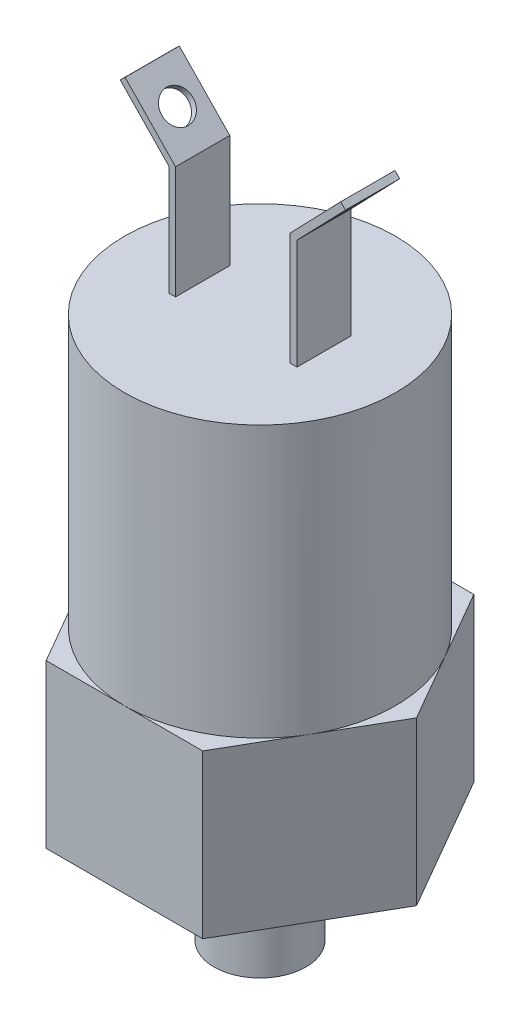
from build123d import *

# Parameters (mm, degrees)
BOSS_EXTRUDE1_DEPTH = 15.24
SKETCH3_R           = 12.7
BOSS_EXTRUDE2_DEPTH = 25.4
SKETCH4_R           = 4.3053
BOSS_EXTRUDE3_DEPTH = 10.16
EXTRUDE_THIN1_DEPTH = 2.54
SKETCH6_R           = 1.4605
CUT_EXTRUDE1_DEPTH  = 0.635


with BuildPart() as part:
    # Sketch2 → Boss-Extrude1 (new body)
    with BuildSketch(Plane(origin=(0, 0, 0), x_dir=(1, 0, 0), z_dir=(0, 1, 0))):
        Polygon((7.332348419, 12.7), (-7.332348419, 12.7), (-14.664696837, 0), (-7.332348419, -12.7), (7.332348419, -12.7), (14.664696837, 0), align=None)
    extrude(amount=BOSS_EXTRUDE1_DEPTH)

    # Sketch3 → Boss-Extrude2 (add)
    with BuildSketch(Plane(origin=(0, 15.24, 0), x_dir=(1, 0, 0), z_dir=(0, 1, 0))):
        Circle(SKETCH3_R)
    extrude(amount=BOSS_EXTRUDE2_DEPTH)

    # Sketch4 → Boss-Extrude3 (add)
    with BuildSketch(Plane.XZ):
        Circle(SKETCH4_R)
    extrude(amount=BOSS_EXTRUDE3_DEPTH)

    # Sketch5 → Extrude-Thin1 (add, symmetric)
    with BuildSketch(Plane.XY):
        Polygon((6.008182396, 40.64), (6.008182396, 50.946997676), (10.555270964, 55.659540341), (10.098307994, 56.100459659), (5.373182396, 51.203401761), (5.373182396, 40.64), align=None)
    extrude_thin1 = extrude(amount=EXTRUDE_THIN1_DEPTH, both=True)

    # Sketch6 → Cut-Extrude1 (cut)
    with BuildSketch(Plane(origin=(-22.802787707, 22.00219768, 0), x_dir=(0, 0, 1), z_dir=(-0.719626724, 0.69436113, 0))):
        with Locations((0, 43.980763894)):
            Circle(SKETCH6_R)
    cut_extrude1 = extrude(amount=-CUT_EXTRUDE1_DEPTH, mode=Mode.SUBTRACT)

    # Mirror1: Extrude-Thin1, Cut-Extrude1 across plane
    add(extrude_thin1.mirror(Plane(origin=(0, 0, 0), x_dir=(0, 0, 1), z_dir=(1, 0, 0))))
    add(cut_extrude1.mirror(Plane(origin=(0, 0, 0), x_dir=(0, 0, 1), z_dir=(1, 0, 0))), mode=Mode.SUBTRACT)


solid = part.part
